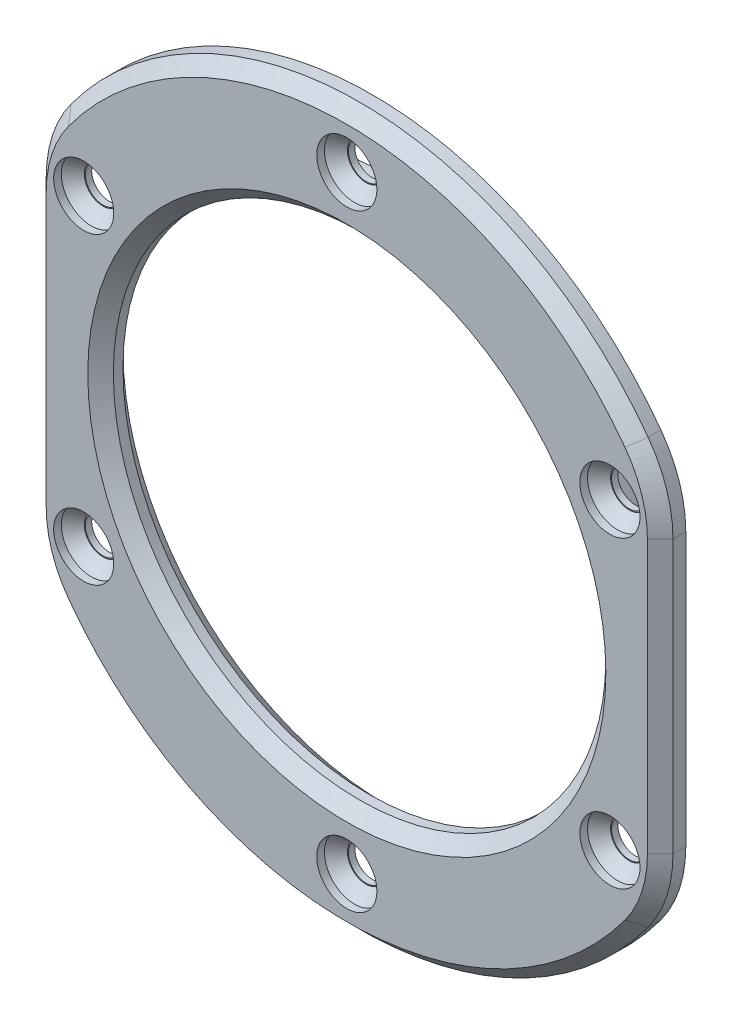
from build123d import *

# Parameters (mm, degrees)
SKETCH1_R           = 28
SKETCH1_R_2         = 19.25
BOSS_EXTRUDE1_DEPTH = 2
SKETCH2_R           = 22.15
SKETCH2_R_2         = 19.25
BOSS_EXTRUDE2_DEPTH = 1
SKETCH3_R           = 1.375
CUT_EXTRUDE1_DEPTH  = 4
SKETCH4_W           = 12.894615696
SKETCH4_H           = 54.223512158
CUT_EXTRUDE2_DEPTH  = 4
FILLET1_R           = 10
SKETCH5_R           = 2.35
CUT_EXTRUDE3_DEPTH  = 1.5
CHAMFER2_SIZE       = 0.9
CHAMFER1_SIZE       = 1
CHAMFER3_SIZE       = 1.25


with BuildPart() as part:
    # Sketch1 → Boss-Extrude1 (new body)
    with BuildSketch(Plane.XY):
        Circle(SKETCH1_R)
        Circle(SKETCH1_R_2, mode=Mode.SUBTRACT)
    extrude(amount=BOSS_EXTRUDE1_DEPTH)

    # Sketch2 → Boss-Extrude2 (add)
    with BuildSketch(Plane(origin=(0, 0, 0), x_dir=(-1, 0, 0), z_dir=(0, 0, -1))):
        Circle(SKETCH2_R)
        Circle(SKETCH2_R_2, mode=Mode.SUBTRACT)
    extrude(amount=BOSS_EXTRUDE2_DEPTH)

    # Sketch3 → Cut-Extrude1 (cut, through all)
    with BuildSketch(Plane.XY.offset(2)):
        with Locations((0, 23.75)):
            Circle(SKETCH3_R)
        with Locations((20.56810334, 11.875)):
            Circle(SKETCH3_R)
        with Locations((20.56810334, -11.875)):
            Circle(SKETCH3_R)
        with Locations((0, -23.75)):
            Circle(SKETCH3_R)
        with Locations((-20.56810334, -11.875)):
            Circle(SKETCH3_R)
        with Locations((-20.56810334, 11.875)):
            Circle(SKETCH3_R)
    extrude(amount=-CUT_EXTRUDE1_DEPTH, mode=Mode.SUBTRACT)

    # Sketch4 → Cut-Extrude2 (cut, through all)
    with BuildSketch(Plane.XY.offset(2)):
        with Locations((30.947307848, -0.328141479)):
            Rectangle(SKETCH4_W, SKETCH4_H)
        with Locations((-30.947307848, -0.328141479)):
            Rectangle(SKETCH4_W, SKETCH4_H)
    extrude(amount=-CUT_EXTRUDE2_DEPTH, mode=Mode.SUBTRACT)

    # Fillet1
    fillet1_edges = [part.edges().sort_by_distance(p)[0] for p in [
        (24.5, -13.555441712, 1),
        (24.5, 13.555441712, 1),
        (-24.5, 13.555441712, 1),
        (-24.5, -13.555441712, 1),
    ]]
    fillet(fillet1_edges, radius=FILLET1_R)

    # Sketch5 → Cut-Extrude3 (cut)
    with BuildSketch(Plane.XY.offset(2)):
        with Locations((0, 23.75)):
            Circle(SKETCH5_R)
        with Locations((20.56810334, 11.875)):
            Circle(SKETCH5_R)
        with Locations((-20.56810334, 11.875)):
            Circle(SKETCH5_R)
        with Locations((20.56810334, -11.875)):
            Circle(SKETCH5_R)
        with Locations((0, -23.75)):
            Circle(SKETCH5_R)
        with Locations((-20.56810334, -11.875)):
            Circle(SKETCH5_R)
    extrude(amount=-CUT_EXTRUDE3_DEPTH, mode=Mode.SUBTRACT)

    # Chamfer2
    chamfer2_edges = [part.edges().sort_by_distance(p)[0] for p in [
        (-2.35, 23.75, 0.5),
        (-22.91810334, -11.875, 0.5),
        (-2.35, -23.75, 0.5),
        (18.21810334, -11.875, 0.5),
        (-22.91810334, 11.875, 0.5),
        (18.21810334, 11.875, 0.5),
    ]]
    chamfer(chamfer2_edges, length=CHAMFER2_SIZE)

    # Chamfer1
    chamfer1_edges = [part.edges().sort_by_distance(p)[0] for p in [
        (-19.25, 0, 2),
        (0, 28, 2),
        (24.5, 0, 2),
        (-24.5, 0, 2),
        (0, -28, 2),
        (-24.001461876, 13.783412326, 2),
        (-24.001461876, -13.783412326, 2),
        (24.001461876, -13.783412326, 2),
        (24.001461876, 13.783412326, 2),
    ]]
    chamfer(chamfer1_edges, length=CHAMFER1_SIZE)

    # Chamfer3
    chamfer3_edges = [part.edges().sort_by_distance(p)[0] for p in [
        (19.25, 0, -1),
    ]]
    chamfer(chamfer3_edges, length=CHAMFER3_SIZE)


solid = part.part
